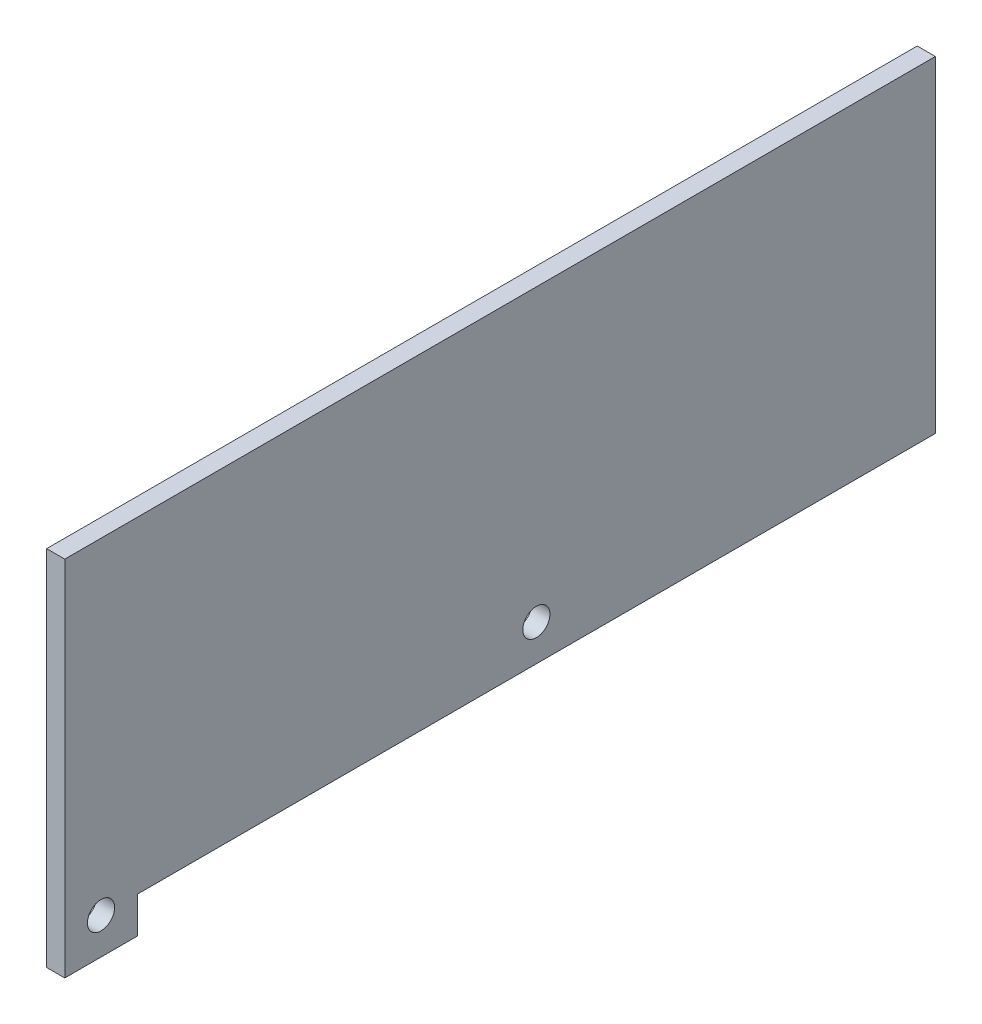
from build123d import *

# Parameters (mm, degrees)
BOSS_EXTRUDE1_DEPTH = 6.35
CUT_EXTRUDE1_REACH  = 14.7
SKETCH2_R           = 9.525


with BuildPart() as part:
    # Sketch1 → Boss-Extrude1 (new body, symmetric)
    with BuildSketch(Plane(origin=(0, 0, 0), x_dir=(0, 0, -1), z_dir=(1, 0, 0))):
        Polygon((0, 0), (50.8, 0), (50.8, 25.4), (609.6, 25.4), (609.6, 254), (0, 254), align=None)
    extrude(amount=BOSS_EXTRUDE1_DEPTH, both=True)

    # Sketch2 → Cut-Extrude1 (cut, up to next)
    with BuildSketch(Plane(origin=(6.35, 0, 0), x_dir=(0, 0, -1), z_dir=(1, 0, 0)), mode=Mode.PRIVATE) as cut_extrude1_sk1:
        with Locations((25.4, 25.4)):
            Circle(SKETCH2_R)
    cut_extrude1_tool1 = extrude(cut_extrude1_sk1.sketch, amount=-CUT_EXTRUDE1_REACH, mode=Mode.PRIVATE) & part.part
    add(cut_extrude1_tool1.solids().sort_by_distance((6.35, 25.4, -25.4))[0], mode=Mode.SUBTRACT)
    # Sketch2 → Cut-Extrude1 (cut, up to next)
    with BuildSketch(Plane(origin=(6.35, 0, 0), x_dir=(0, 0, -1), z_dir=(1, 0, 0)), mode=Mode.PRIVATE) as cut_extrude1_sk2:
        with Locations((330.2, 50.8)):
            Circle(SKETCH2_R)
    cut_extrude1_tool2 = extrude(cut_extrude1_sk2.sketch, amount=-CUT_EXTRUDE1_REACH, mode=Mode.PRIVATE) & part.part
    add(cut_extrude1_tool2.solids().sort_by_distance((6.35, 50.8, -330.2))[0], mode=Mode.SUBTRACT)


solid = part.part
